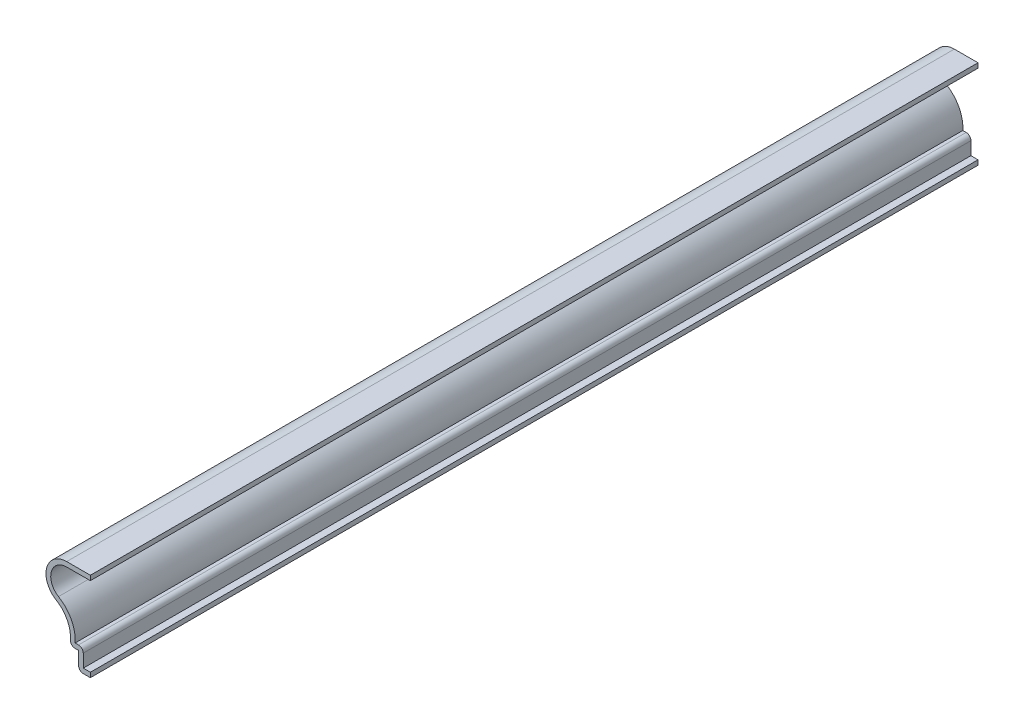
from build123d import *

# Parameters (mm, degrees)
EXTRUDE_THIN1_DEPTH = 238.125
FILLET1_R           = 1.27


with BuildPart() as part:
    # Sketch1 → Extrude-Thin1 (new body)
    with BuildSketch(Plane.XY):
        with BuildLine():
            Line((0, 0), (-3.175, 0))
            Line((-3.175, 0), (-3.175, 4.7625))
            Line((-3.175, 4.7625), (-5.55625, 4.7625))
            ThreePointArc((-5.55625, 4.7625), (-5.936639641, 9.724124929), (-9.196056015, 13.484260978))
            ThreePointArc((-9.196056015, 13.484260978), (-11.70659771, 19.732317421), (-6.35, 23.8125))
            Line((-6.35, 23.8125), (0, 23.8125))
            Line((0, 23.8125), (0, 22.5425))
            Line((0, 22.5425), (-6.35, 22.5425))
            ThreePointArc((-6.35, 22.5425), (-10.48223252, 19.394930582), (-8.545528926, 14.575001326))
            ThreePointArc((-8.545528926, 14.575001326), (-5.103452481, 10.935459111), (-4.076247664, 6.0325))
            Line((-4.076247664, 6.0325), (-1.905, 6.0325))
            Line((-1.905, 6.0325), (-1.905, 1.27))
            Line((-1.905, 1.27), (0, 1.27))
            Line((0, 1.27), (0, 0))
        make_face()
    extrude(amount=-EXTRUDE_THIN1_DEPTH)

    # Fillet1
    fillet1_edges = [part.edges().sort_by_distance(p)[0] for p in [
        (-1.905, 6.0325, -119.0625),
        (-3.175, 0, -119.0625),
        (-5.55625, 4.7625, -119.0625),
    ]]
    fillet(fillet1_edges, radius=FILLET1_R)


solid = part.part
